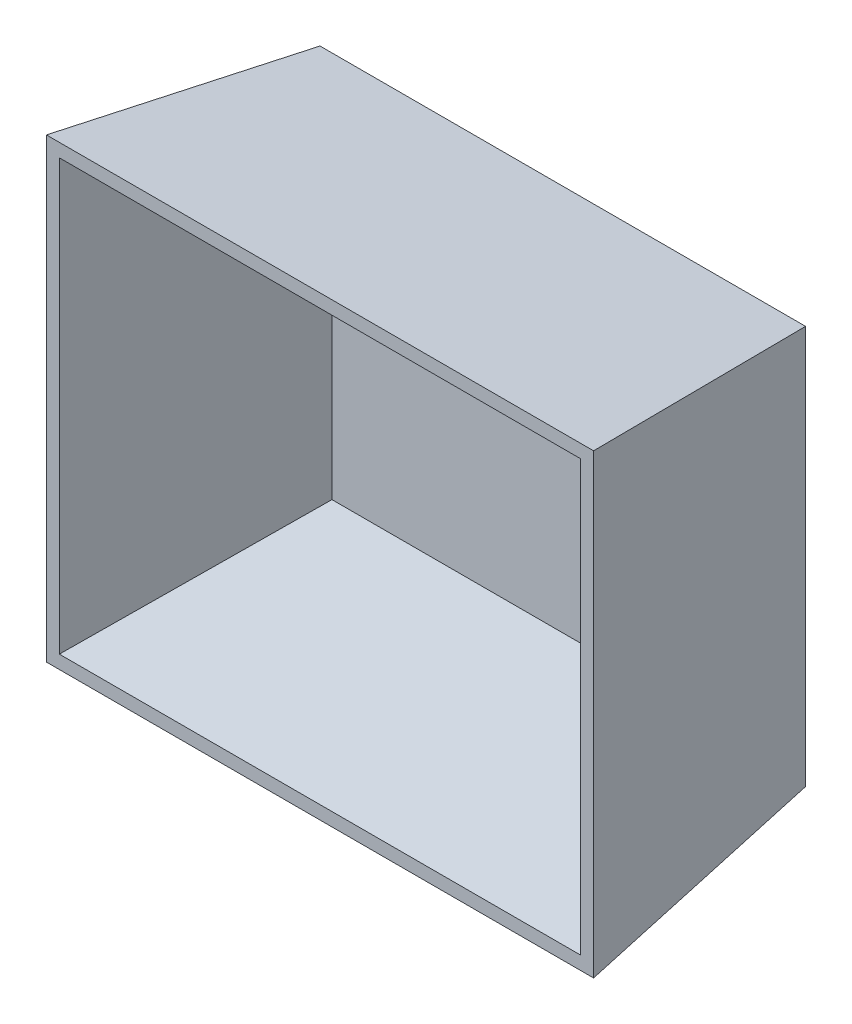
from build123d import *

# Parameters (mm, degrees)
SKETCH_2_W = 151
SKETCH_2_H = 126
SKETCH_1_W = 134
SKETCH_1_H = 110
SKETCH_3_W = 143.875710796
SKETCH_3_H = 118.62726712
SKETCH_4_W = 125.407231672
SKETCH_4_H = 101.536444544


with BuildPart() as part:
    # 草图2 → 放样2 section 0
    with BuildSketch(Plane.XY.offset(67)):
        with Locations((67, 55)):
            Rectangle(SKETCH_2_W, SKETCH_2_H)
    # 草图1 → 放样2 section 1
    with BuildSketch(Plane.XY):
        with Locations((67, 55)):
            Rectangle(SKETCH_1_W, SKETCH_1_H)
    loft()

    # 草图3 → 切除-放样3 section 0
    with BuildSketch(Plane.XY.offset(67)):
        with Locations((67, 55)):
            Rectangle(SKETCH_3_W, SKETCH_3_H)
    # 草图4 → 切除-放样3 section 1
    with BuildSketch(Plane(origin=(0, 0, 1), x_dir=(-1, 0, 0), z_dir=(0, 0, -1))):
        with Locations((-67, 55)):
            Rectangle(SKETCH_4_W, SKETCH_4_H)
    loft(mode=Mode.SUBTRACT)


solid = part.part
